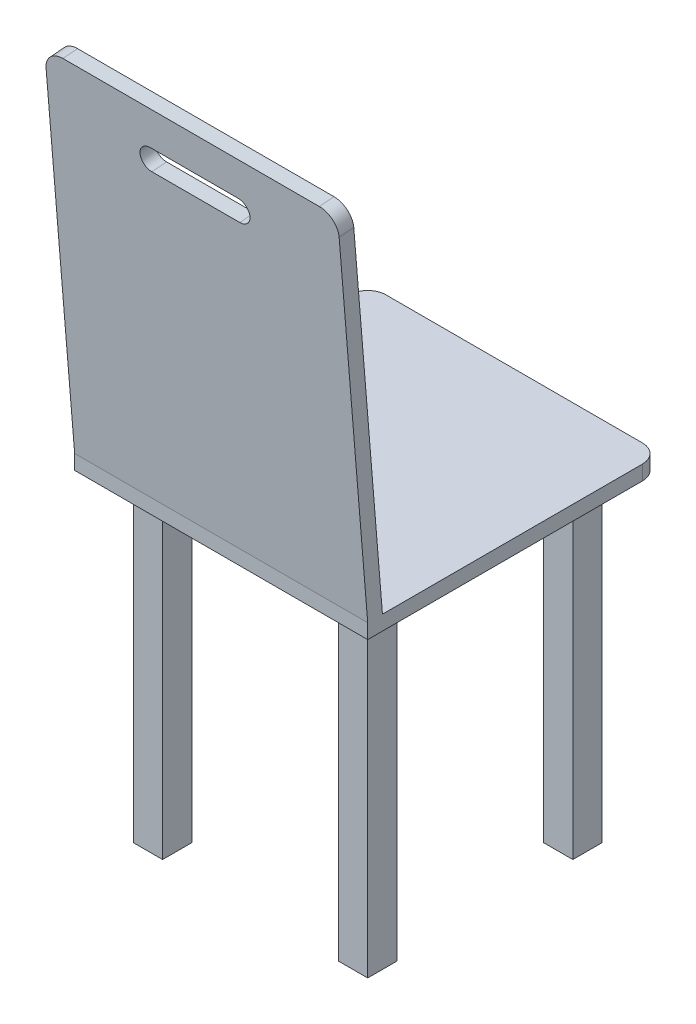
from build123d import *

# Parameters (mm, degrees)
BOSS_EXTRUDE2_DEPTH = 40
FILLET3_R           = 2.5
CUT_EXTRUDE2_DEPTH  = 3
SKETCH6_W           = 4
SKETCH6_H           = 4
BOSS_EXTRUDE3_DEPTH = 44
SKETCH7_W           = 4
SKETCH7_H           = 4
BOSS_EXTRUDE5_DEPTH = 44
SKETCH8_W           = 4
SKETCH8_H           = 4
BOSS_EXTRUDE6_DEPTH = 44
SKETCH9_W           = 4
SKETCH9_H           = 4
BOSS_EXTRUDE7_DEPTH = 44


with BuildPart() as part:
    # Sketch3 → Boss-Extrude2 (new body)
    with BuildSketch(Plane(origin=(0, 0, 0), x_dir=(0, 0, -1), z_dir=(1, 0, 0))):
        Polygon((0, 0), (40, 0), (40, 2), (2.013480299, 2), (-2.104920658, 52.164196826), (-4.104920658, 52), (0, 2), align=None)
    extrude(amount=BOSS_EXTRUDE2_DEPTH)

    # Fillet3
    fillet3_edges = [part.edges().sort_by_distance(p)[0] for p in [
        (40, 1, -40),
        (40, 52.082098413, 3.104920658),
        (0, 52.082098413, 3.104920658),
        (0, 1, -40),
    ]]
    fillet(fillet3_edges, radius=FILLET3_R)

    # Sketch5 → Cut-Extrude2 (cut)
    with BuildSketch(Plane(origin=(0, 0.013390048, -0.163097525), x_dir=(1, 0, 0), z_dir=(0, -0.081823126, 0.996646866))):
        with BuildLine():
            Line((14, 47.161514486), (26, 47.161514486))
            ThreePointArc((26, 47.161514486), (27.5, 45.661514486), (26, 44.161514486))
            Line((26, 44.161514486), (14, 44.161514486))
            ThreePointArc((14, 44.161514486), (12.5, 45.661514486), (14, 47.161514486))
        make_face()
    extrude(amount=-CUT_EXTRUDE2_DEPTH, mode=Mode.SUBTRACT)

    # Sketch6 → Boss-Extrude3 (add)
    with BuildSketch(Plane.XZ):
        with Locations((34, -6)):
            Rectangle(SKETCH6_W, SKETCH6_H)
    extrude(amount=BOSS_EXTRUDE3_DEPTH)

    # Sketch7 → Boss-Extrude5 (add)
    with BuildSketch(Plane.XZ):
        with Locations((6, -6)):
            Rectangle(SKETCH7_W, SKETCH7_H)
    extrude(amount=BOSS_EXTRUDE5_DEPTH)

    # Sketch8 → Boss-Extrude6 (add)
    with BuildSketch(Plane.XZ):
        with Locations((6, -34)):
            Rectangle(SKETCH8_W, SKETCH8_H)
    extrude(amount=BOSS_EXTRUDE6_DEPTH)

    # Sketch9 → Boss-Extrude7 (add)
    with BuildSketch(Plane.XZ):
        with Locations((34, -34)):
            Rectangle(SKETCH9_W, SKETCH9_H)
    extrude(amount=BOSS_EXTRUDE7_DEPTH)


solid = part.part
